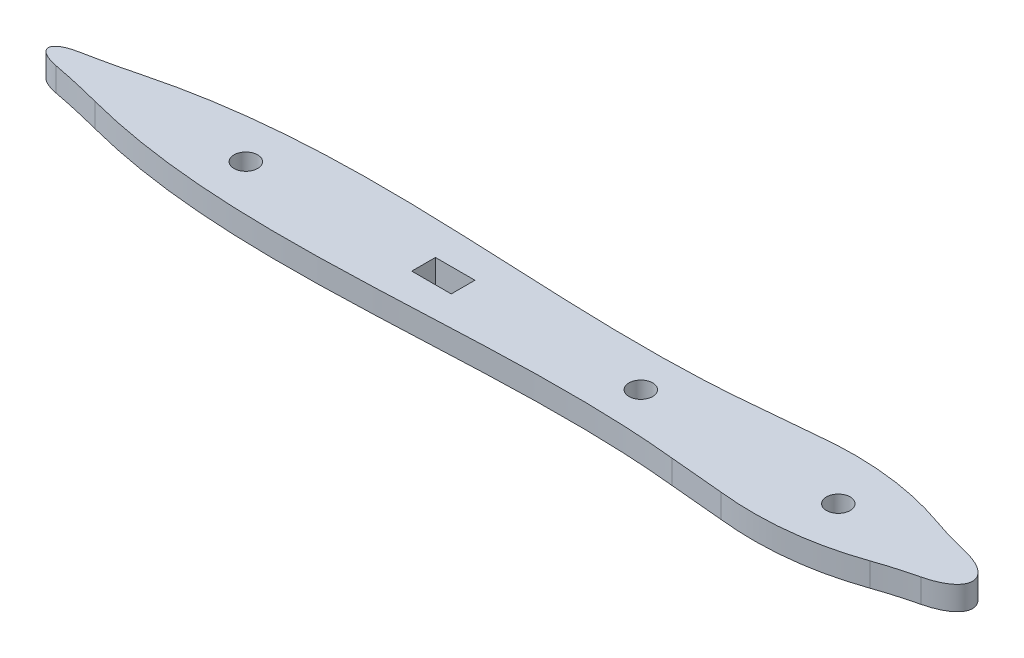
from build123d import *

# Parameters (mm, degrees)
ESBO_O1_R                = 1.5
ESBO_O1_W                = 5
ESBO_O1_H                = 3
RESSALTO_EXTRUS_O1_DEPTH = 3


with BuildPart() as part:
    # Esboço1 → Ressalto-extrusão1 (new body)
    with BuildSketch(Plane(origin=(0, 0, 0), x_dir=(1, 0, 0), z_dir=(0, 1, 0))):
        with BuildLine():
            Line((-15.5324261, 5.526900759), (-8.701477822, 6.15))
            add(Edge.make_bspline(
                [(8.269723742, 4.259468977), (2.834912713, 6.157347241), (-2.82215339, 6.787527354), (-8.701477822, 6.15)],
                knots=[0.35388944, 0.35388944, 0.35388944, 0.35388944, 1, 1, 1, 1], degree=3))
            ThreePointArc((8.269723742, 4.259468977), (10.737611567, 3.46879666), (13.24315076, 2.807051708))
            add(Edge.make_bspline(
                [(13.243153259, -2.80704963), (25.10877849, 2.12e-06), (13.24315076, 2.807051708)],
                knots=[5.194112275, 5.194112275, 5.194112275, 7.372258742, 7.372258742, 7.372258742], degree=2, weights=[1, 0.463306864, 1]))
            ThreePointArc((13.243153259, -2.80704963), (10.737612779, -3.468795552), (8.269723742, -4.259468977))
            add(Edge.make_bspline(
                [(8.269723742, -4.259468977), (2.834913243, -6.15734876), (-2.822153925, -6.787525817), (-8.701477822, -6.15)],
                knots=[0.35388944, 0.35388944, 0.35388944, 0.35388944, 1, 1, 1, 1], degree=3))
            Line((-8.701477822, -6.15), (-15.5324261, -5.526900759))
            add(Edge.make_bspline(
                [(-91.135478662, -2.939356415), (-85.814709071, -4.330378827), (-60.917561227, -7.97508816), (-35.132432713, -3.48955228), (-15.5324261, -5.526900759)],
                knots=[0.107974898, 0.107974898, 0.107974898, 0.107974898, 0.300967181, 1, 1, 1, 1], degree=3))
            ThreePointArc((-91.135478662, -2.939356415), (-94.330524557, -2.159963767), (-97.549471293, -1.486054958))
            add(Edge.make_bspline(
                [(-97.549471293, 1.486054958), (-105.279311729, 0), (-97.549471293, -1.486054958)],
                knots=[5.195092838, 5.195092838, 5.195092838, 7.371277776, 7.371277776, 7.371277776], degree=2, weights=[1, 0.464175793, 1]))
            ThreePointArc((-97.549471293, 1.486054958), (-94.330524557, 2.159963767), (-91.135478662, 2.939356415))
            add(Edge.make_bspline(
                [(-91.135478662, 2.939356415), (-85.814709071, 4.330378827), (-60.917561227, 7.97508816), (-35.132432713, 3.48955228), (-15.5324261, 5.526900759)],
                knots=[0.107974898, 0.107974898, 0.107974898, 0.107974898, 0.300967181, 1, 1, 1, 1], degree=3))
        make_face()
        Circle(ESBO_O1_R, mode=Mode.SUBTRACT)
        with Locations((-75, 0)):
            Circle(ESBO_O1_R, mode=Mode.SUBTRACT)
        with Locations((-25, 0)):
            Circle(ESBO_O1_R, mode=Mode.SUBTRACT)
        with Locations((-50, 0)):
            Rectangle(ESBO_O1_W, ESBO_O1_H, mode=Mode.SUBTRACT)
    extrude(amount=RESSALTO_EXTRUS_O1_DEPTH)


solid = part.part
